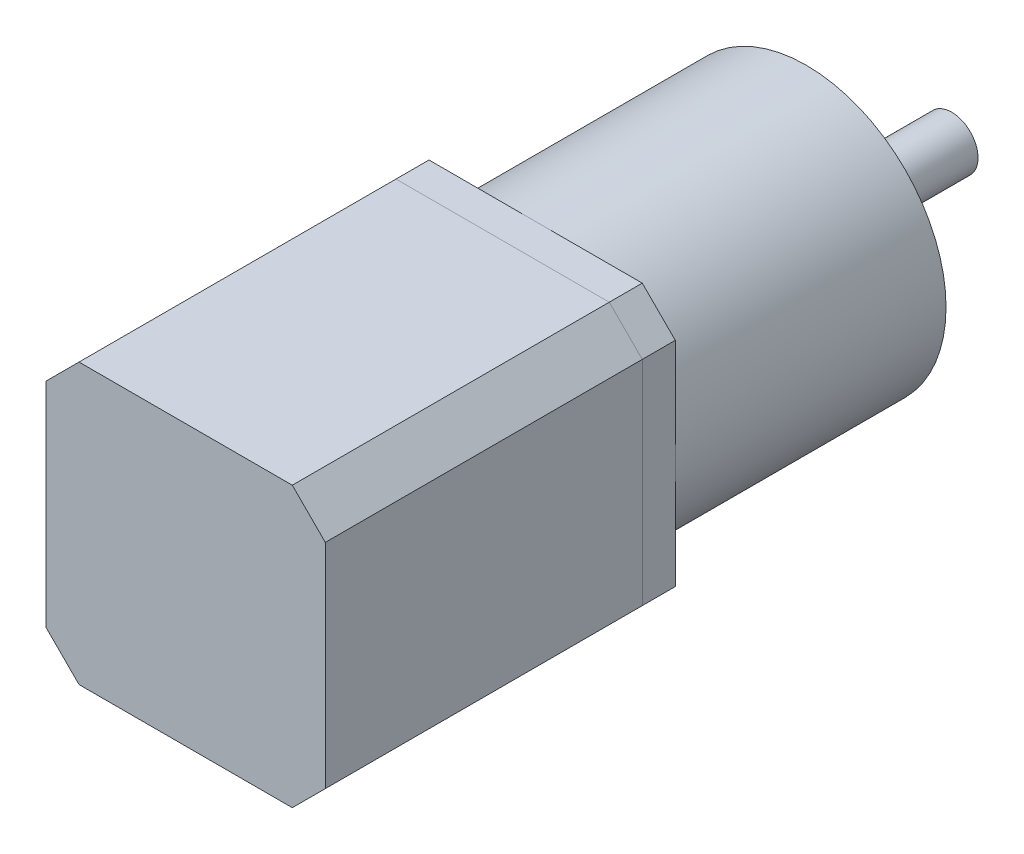
from build123d import *

# Parameters (mm, degrees)
SKETCH1_W           = 42.3
SKETCH1_H           = 42.3
BOSS_EXTRUDE1_DEPTH = 48
CHAMFER1_SIZE       = 5
SKETCH2_W           = 42.3
SKETCH2_H           = 42.3
BOSS_EXTRUDE2_DEPTH = 5
CHAMFER2_SIZE       = 5
SKETCH3_R           = 21.15
BOSS_EXTRUDE3_DEPTH = 41
SKETCH4_R           = 11
BOSS_EXTRUDE4_DEPTH = 2
SKETCH5_R           = 4
BOSS_EXTRUDE5_DEPTH = 20
SKETCH6_R           = 6.210975092
BOSS_EXTRUDE6_DEPTH = 0.5
SKETCH7_R           = 1.5
CUT_EXTRUDE2_DEPTH  = 10


with BuildPart() as part:
    # Sketch1 → Boss-Extrude1 (new body)
    with BuildSketch(Plane.XY):
        Rectangle(SKETCH1_W, SKETCH1_H)
    extrude(amount=BOSS_EXTRUDE1_DEPTH)

    # Chamfer1
    chamfer1_edges = [part.edges().sort_by_distance(p)[0] for p in [
        (21.15, -21.15, 24),
        (-21.15, -21.15, 24),
        (-21.15, 21.15, 24),
        (21.15, 21.15, 24),
    ]]
    chamfer(chamfer1_edges, length=CHAMFER1_SIZE)


with BuildPart() as body_2:
    # Sketch2 → Boss-Extrude2 (new body)
    with BuildSketch(Plane(origin=(0, 0, 0), x_dir=(-1, 0, 0), z_dir=(0, 0, -1))):
        Rectangle(SKETCH2_W, SKETCH2_H)
    extrude(amount=BOSS_EXTRUDE2_DEPTH)

    # Chamfer2
    chamfer2_edges = [body_2.edges().sort_by_distance(p)[0] for p in [
        (-21.15, -21.15, -2.5),
        (21.15, -21.15, -2.5),
        (21.15, 21.15, -2.5),
        (-21.15, 21.15, -2.5),
    ]]
    chamfer(chamfer2_edges, length=CHAMFER2_SIZE)


with BuildPart() as body_3:
    # Sketch3 → Boss-Extrude3 (new body)
    with BuildSketch(Plane(origin=(0, 0, -5), x_dir=(-1, 0, 0), z_dir=(0, 0, -1))):
        Circle(SKETCH3_R)
    extrude(amount=BOSS_EXTRUDE3_DEPTH)

    # Sketch7 → Cut-Extrude2 (cut)
    with BuildSketch(Plane(origin=(0, 0, -46), x_dir=(-1, 0, 0), z_dir=(0, 0, -1))):
        with Locations((-17.5, 0)):
            Circle(SKETCH7_R)
        with Locations((0, 17.5)):
            Circle(SKETCH7_R)
        with Locations((17.5, 0)):
            Circle(SKETCH7_R)
        with Locations((0, -17.5)):
            Circle(SKETCH7_R)
    extrude(amount=-CUT_EXTRUDE2_DEPTH, mode=Mode.SUBTRACT)


with BuildPart() as body_4:
    # Sketch4 → Boss-Extrude4 (new body)
    with BuildSketch(Plane(origin=(0, 0, -46), x_dir=(-1, 0, 0), z_dir=(0, 0, -1))):
        Circle(SKETCH4_R)
    extrude(amount=BOSS_EXTRUDE4_DEPTH)


with BuildPart() as body_5:
    # Sketch5 → Boss-Extrude5 (new body)
    with BuildSketch(Plane(origin=(0, 0, -48), x_dir=(-1, 0, 0), z_dir=(0, 0, -1))):
        Circle(SKETCH5_R)
    extrude(amount=BOSS_EXTRUDE5_DEPTH)


with BuildPart() as body_6:
    # Sketch6 → Boss-Extrude6 (new body)
    with BuildSketch(Plane(origin=(0, 0, -48), x_dir=(-1, 0, 0), z_dir=(0, 0, -1))):
        Circle(SKETCH6_R)
    extrude(amount=BOSS_EXTRUDE6_DEPTH)


solid = Compound([part.part, body_2.part, body_3.part, body_4.part, body_5.part, body_6.part])
